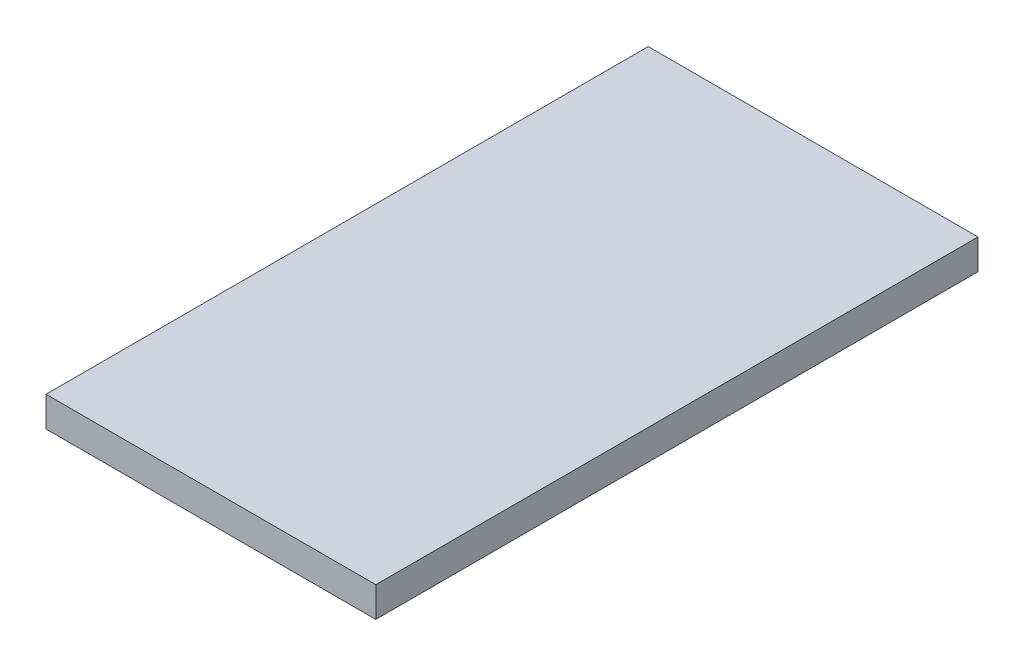
from build123d import *

# Parameters (mm, degrees)
SKETCH1_W           = 23
SKETCH1_H           = 42
BOSS_EXTRUDE2_DEPTH = 2.1


with BuildPart() as part:
    # Sketch1 → Boss-Extrude2 (new body)
    with BuildSketch(Plane(origin=(0, 0, 0), x_dir=(1, 0, 0), z_dir=(0, 1, 0))):
        Rectangle(SKETCH1_W, SKETCH1_H)
    extrude(amount=BOSS_EXTRUDE2_DEPTH)


solid = part.part
